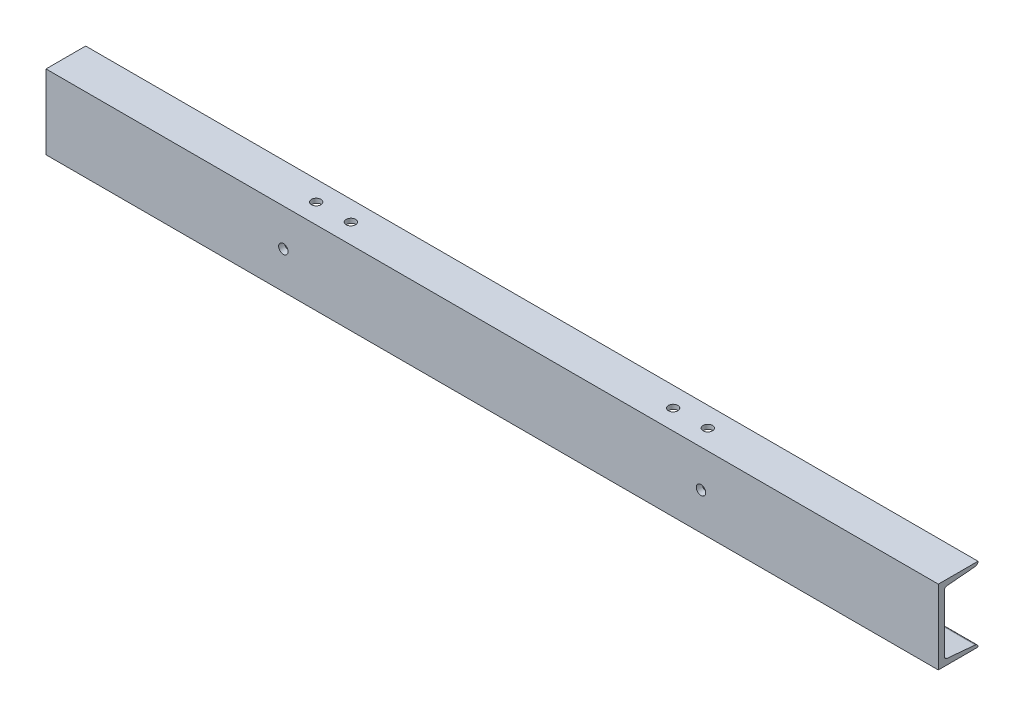
from build123d import *

# Parameters (mm, degrees)
STRUCTURAL_MEMBER1_DEPTH = 900
SKETCH12_R               = 4.7625
CUT_EXTRUDE1_DEPTH       = 454.327971782
CUT_EXTRUDE2_DEPTH       = 40
SKETCH16_R               = 4.7625
CUT_EXTRUDE3_DEPTH       = 454.327971881
SKETCH19_OUTSIDE_W       = 1082.8
SKETCH19_OUTSIDE_H       = 257.8
SKETCH19_OUTSIDE_W_2     = 900
SKETCH19_OUTSIDE_H_2     = 75
SKETCH19_OUTSIDE_R       = 4.7625
CUT_EXTRUDE5_DEPTH       = 454.327971881


with BuildPart() as part:
    # Sketch18 → Structural Member1 (new body)
    with BuildSketch(Plane(origin=(-450, 0, 0), x_dir=(0, 0, 1), z_dir=(1, 0, 0))):
        with BuildLine():
            Line((0, 37.5), (0, -37.5))
            Line((0, -37.5), (-40, -37.5))
            Line((-40, -37.5), (-40, -37.246949676))
            ThreePointArc((-40, -37.246949676), (-39.212582687, -35.220998578), (-37.263681431, -34.258560126))
            Line((-37.263681431, -34.258560126), (-8.736318569, -31.741439874))
            ThreePointArc((-8.736318569, -31.741439874), (-6.787417313, -30.779001422), (-6, -28.753050324))
            Line((-6, -28.753050324), (-6, 28.753050324))
            ThreePointArc((-6, 28.753050324), (-6.787417313, 30.779001422), (-8.736318569, 31.741439874))
            Line((-8.736318569, 31.741439874), (-37.263681431, 34.258560126))
            ThreePointArc((-37.263681431, 34.258560126), (-39.212582687, 35.220998578), (-40, 37.246949676))
            Line((-40, 37.246949676), (-40, 37.5))
            Line((-40, 37.5), (0, 37.5))
        make_face()
    extrude(amount=STRUCTURAL_MEMBER1_DEPTH)

    # Sketch12 → Cut-Extrude1 (cut, through all)
    with BuildSketch(Plane(origin=(0, 0, 0), x_dir=(1, 0, 0), z_dir=(0, 1, 0))):
        with Locations(Location((-425, 20, 0), (0, 0, 270))):
            Circle(SKETCH12_R)
        with Locations(Location((425, 20, 0), (0, 0, 270))):
            Circle(SKETCH12_R)
    extrude(amount=-CUT_EXTRUDE1_DEPTH, mode=Mode.SUBTRACT)

    # Sketch15 → Cut-Extrude2 (cut)
    with BuildSketch(Plane(origin=(0, 0, -6), x_dir=(-1, 0, 0), z_dir=(0, 0, -1))):
        with BuildLine():
            Line((-412.5, 22.5), (-437.5, 22.5))
            ThreePointArc((-437.5, 22.5), (-442.5, 27.5), (-437.5, 32.5))
            Line((-437.5, 32.5), (-412.5, 32.5))
            ThreePointArc((-412.5, 32.5), (-407.5, 27.5), (-412.5, 22.5))
        make_face()
        with BuildLine():
            Line((412.5, 22.5), (437.5, 22.5))
            ThreePointArc((437.5, 22.5), (442.5, 27.5), (437.5, 32.5))
            Line((437.5, 32.5), (412.5, 32.5))
            ThreePointArc((412.5, 32.5), (407.5, 27.5), (412.5, 22.5))
        make_face()
    extrude(amount=CUT_EXTRUDE2_DEPTH, mode=Mode.SUBTRACT)

    # Sketch16 → Cut-Extrude3 (cut, through all)
    with BuildSketch(Plane(origin=(0, 0, 0), x_dir=(1, 0, 0), z_dir=(0, 1, 0))):
        with Locations(Location((-197.5, 20, 0), (0, 0, 270))):
            Circle(SKETCH16_R)
        with Locations(Location((-162.5, 20, 0), (0, 0, 270))):
            Circle(SKETCH16_R)
        with Locations(Location((162.5, 20, 0), (0, 0, 90))):
            Circle(SKETCH16_R)
        with Locations(Location((197.5, 20, 0), (0, 0, 90))):
            Circle(SKETCH16_R)
    extrude(amount=CUT_EXTRUDE3_DEPTH, mode=Mode.SUBTRACT)

    # Sketch19 outside → Cut-Extrude5 (cut, through all)
    with BuildSketch(Plane.XY):
        Rectangle(SKETCH19_OUTSIDE_W, SKETCH19_OUTSIDE_H)
        Rectangle(SKETCH19_OUTSIDE_W_2, SKETCH19_OUTSIDE_H_2, mode=Mode.SUBTRACT)
        with Locations((210.6, 0)):
            Circle(SKETCH19_OUTSIDE_R)
        with Locations((-210.6, 0)):
            Circle(SKETCH19_OUTSIDE_R)
    extrude(amount=-CUT_EXTRUDE5_DEPTH, mode=Mode.SUBTRACT)


solid = part.part
